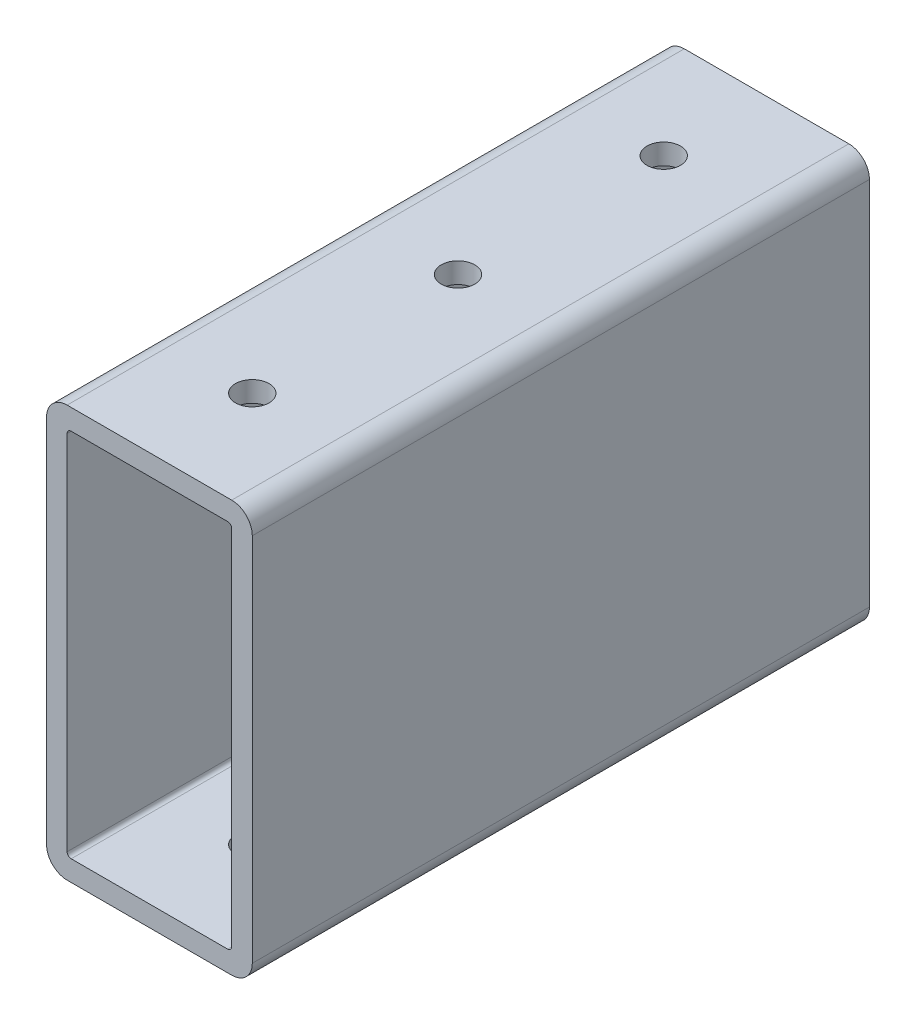
from build123d import *

# Parameters (mm, degrees)
SKETCH1_W                 = 76.2
SKETCH1_H                 = 50.8
BOSS_EXTRUDE1_DEPTH       = 25.4
SKETCH2_W                 = 20.32
SKETCH2_H                 = 45.72
CUT_EXTRUDE1_DEPTH        = 77.2
F_6_CLEARANCE_HOLE1_D     = 4.1402
F_6_CLEARANCE_HOLE1_DEPTH = 50.8
F_6_CLEARANCE_HOLE2_D     = 4.1402
F_6_CLEARANCE_HOLE2_DEPTH = 50.8
FILLET1_R                 = 0.5
FILLET2_R                 = 2.54


with BuildPart() as part:
    # Sketch1 → Boss-Extrude1 (new body)
    with BuildSketch(Plane(origin=(12.7, 0, 0), x_dir=(0, 0, -1), z_dir=(1, 0, 0))):
        Rectangle(SKETCH1_W, SKETCH1_H)
    extrude(amount=-BOSS_EXTRUDE1_DEPTH)

    # Sketch2 → Cut-Extrude1 (cut, through all)
    with BuildSketch(Plane(origin=(0, 0, -38.1), x_dir=(-1, 0, 0), z_dir=(0, 0, -1))):
        Rectangle(SKETCH2_W, SKETCH2_H)
    extrude(amount=-CUT_EXTRUDE1_DEPTH, mode=Mode.SUBTRACT)

    # #6 Clearance Hole1
    with Locations(Plane(origin=(0, -25.4, 0), x_dir=(-1, 0, 0), z_dir=(0, -1, 0))):
        with Locations((0, 711.2), (0, 736.6), (0, 685.8), (0, 660.4), (0, 635), (0, 609.6), (0, 584.2), (0, 558.8), (0, 533.4), (0, 508), (0, 482.6), (0, 457.2), (0, 431.8), (0, 406.4), (0, 381), (0, 355.6), (0, 330.2), (0, 304.8), (0, 279.4), (0, 254), (0, 228.6), (0, 203.2), (0, 177.8), (0, 152.4), (0, 127), (0, 101.6), (0, 76.2), (0, 50.8), (0, 25.4), (0, 0), (0, -25.4), (0, -50.8), (0, -76.2), (0, -101.6), (0, -127), (0, -152.4), (0, -177.8), (0, -203.2), (0, -228.6), (0, -254), (0, -279.4), (0, -304.8), (0, -330.2), (0, -355.6), (0, -381), (0, -406.4), (0, -431.8), (0, -457.2), (0, -482.6), (0, -508), (0, -533.4), (0, -558.8), (0, -584.2), (0, -609.6), (0, -635), (0, -660.4), (0, -685.8), (0, -711.2), (0, -736.6)):
            Hole(F_6_CLEARANCE_HOLE1_D / 2, depth=F_6_CLEARANCE_HOLE1_DEPTH)

    # #6 Clearance Hole2
    with Locations(Plane(origin=(0, 25.4, 0), x_dir=(1, 0, 0), z_dir=(0, 1, 0))):
        with Locations((0, 711.2), (0, 736.6), (0, 685.8), (0, 660.4), (0, 635), (0, 609.6), (0, 584.2), (0, 558.8), (0, 533.4), (0, 508), (0, 482.6), (0, 457.2), (0, 431.8), (0, 406.4), (0, 381), (0, 355.6), (0, 330.2), (0, 304.8), (0, 279.4), (0, 254), (0, 228.6), (0, 203.2), (0, 177.8), (0, 152.4), (0, 127), (0, 101.6), (0, 76.2), (0, 50.8), (0, 25.4), (0, 0), (0, -25.4), (0, -50.8), (0, -76.2), (0, -101.6), (0, -127), (0, -152.4), (0, -177.8), (0, -203.2), (0, -228.6), (0, -254), (0, -279.4), (0, -304.8), (0, -330.2), (0, -355.6), (0, -381), (0, -406.4), (0, -431.8), (0, -457.2), (0, -482.6), (0, -508), (0, -533.4), (0, -558.8), (0, -584.2), (0, -609.6), (0, -635), (0, -660.4), (0, -685.8), (0, -711.2), (0, -736.6)):
            Hole(F_6_CLEARANCE_HOLE2_D / 2, depth=F_6_CLEARANCE_HOLE2_DEPTH)

    # Fillet1
    fillet1_edges = [part.edges().sort_by_distance(p)[0] for p in [
        (-10.16, -22.86, 0),
        (10.16, -22.86, 0),
        (10.16, 22.86, 0),
        (-10.16, 22.86, 0),
    ]]
    fillet(fillet1_edges, radius=FILLET1_R)

    # Fillet2
    fillet2_edges = [part.edges().sort_by_distance(p)[0] for p in [
        (-12.7, 25.4, 0),
        (-12.7, -25.4, 0),
        (12.7, 25.4, 0),
        (12.7, -25.4, 0),
    ]]
    fillet(fillet2_edges, radius=FILLET2_R)


solid = part.part
